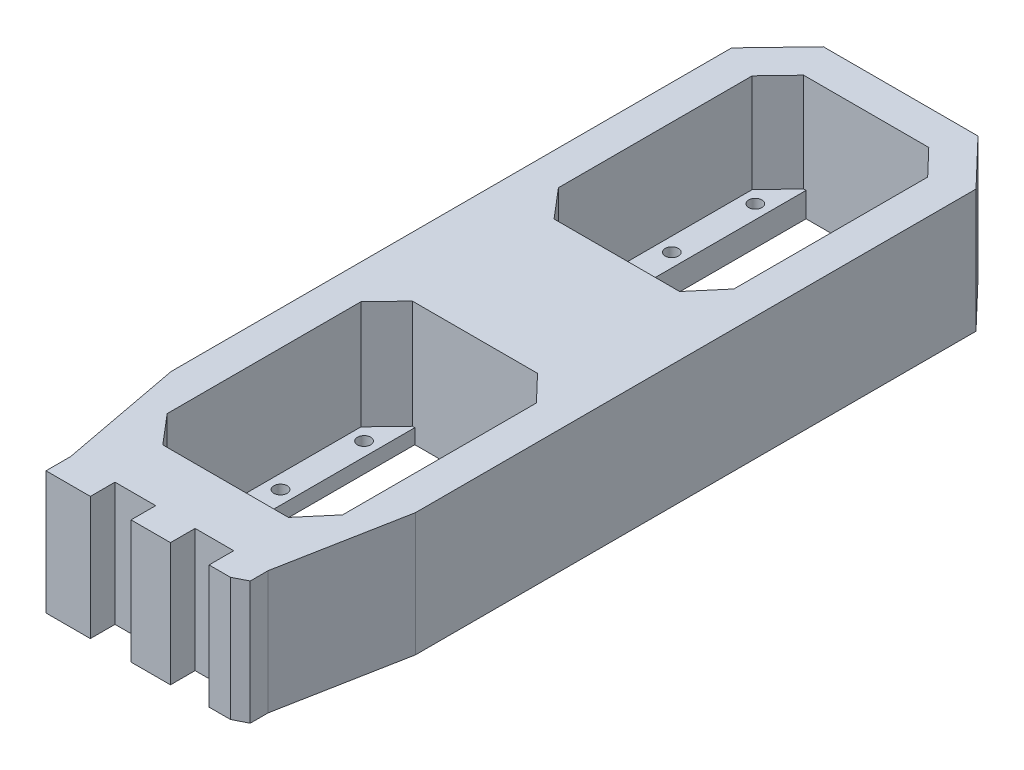
from build123d import *

# Parameters (mm, degrees)
SZKIC1_W                    = 24.4
SZKIC1_H                    = 45
SZKIC1_R                    = 1.35
DODANIE_WYCI_GNI_CIE1_DEPTH = 5
DODANIE_WYCI_GNI_CIE2_DEPTH = 25
SZKIC8_W                    = 8
SZKIC8_H                    = 5
SZKIC8_W_2                  = 9
DODANIE_WYCI_GNI_CIE3_DEPTH = 25
SZKIC1_4_R                  = 1.35
DODANIE_WYCI_GNI_CIE4_DEPTH = 3


with BuildPart() as part:
    # Szkic1 → Dodanie-wyci_gni_cie1 (new body)
    with BuildSketch(Plane(origin=(0, 0, 0), x_dir=(1, 0, 0), z_dir=(0, 1, 0))):
        Polygon((-25.252210447, 194.281753518), (-25.252210447, 80.533497461), (-20.5, 55.3963255), (19.595579106, 55.3963255), (24.347789553, 80.533497461), (24.347789553, 194.281753518), (15.236444388, 203.7963255), (-16.140865282, 203.7963255), align=None)
        with Locations((-0.452210447, 174.2963255)):
            Rectangle(SZKIC1_W, SZKIC1_H, mode=Mode.SUBTRACT)
        with Locations((-15.404420894, 155.2963255)):
            Circle(SZKIC1_R, mode=Mode.SUBTRACT)
        with Locations((-8.952210447, 148.9963255)):
            Circle(SZKIC1_R, mode=Mode.SUBTRACT)
        with Locations((-15.404420894, 172.2963255)):
            Circle(SZKIC1_R, mode=Mode.SUBTRACT)
        with Locations((-15.452210447, 189.2963255)):
            Circle(SZKIC1_R, mode=Mode.SUBTRACT)
        with Locations((8.047789553, 148.9963255)):
            Circle(SZKIC1_R, mode=Mode.SUBTRACT)
        with Locations((14.5, 155.2963255)):
            Circle(SZKIC1_R, mode=Mode.SUBTRACT)
        with Locations((14.5, 172.2963255)):
            Circle(SZKIC1_R, mode=Mode.SUBTRACT)
        with Locations((14.547789553, 189.2963255)):
            Circle(SZKIC1_R, mode=Mode.SUBTRACT)
        Polygon((12.247789553, 117.3963255), (17.347789553, 112.070622628), (17.347789553, 72.740102496), (12.295579106, 66.7963255), (-13.2, 66.7963255), (-18.252210447, 72.740102496), (-18.252210447, 112.070622628), (-13.152210447, 117.3963255), align=None, mode=Mode.SUBTRACT)
    extrude(amount=DODANIE_WYCI_GNI_CIE1_DEPTH)

    # Szkic1_3 → Dodanie-wyci_gni_cie2 (add)
    with BuildSketch(Plane(origin=(0, 0, 0), x_dir=(1, 0, 0), z_dir=(0, 1, 0))):
        Polygon((-20.5, 55.3963255), (19.595579106, 55.3963255), (24.347789553, 80.533497461), (24.347789553, 194.281753518), (15.236444388, 203.7963255), (-16.140865282, 203.7963255), (-25.252210447, 194.281753518), (-25.252210447, 80.533497461), align=None)
        Polygon((-13.152210447, 117.3963255), (12.247789553, 117.3963255), (17.347789553, 112.070622628), (17.347789553, 72.740102496), (12.295579106, 66.7963255), (-13.2, 66.7963255), (-18.252210447, 72.740102496), (-18.252210447, 112.070622628), align=None, mode=Mode.SUBTRACT)
        Polygon((12.247789553, 196.7963255), (17.347789553, 191.470622628), (17.347789553, 152.140102496), (12.295579106, 146.1963255), (-13.2, 146.1963255), (-18.252210447, 152.140102496), (-18.252210447, 191.470622628), (-13.152210447, 196.7963255), align=None, mode=Mode.SUBTRACT)
    extrude(amount=DODANIE_WYCI_GNI_CIE2_DEPTH)

    # Szkic8 → Dodanie-wyci_gni_cie3 (add)
    with BuildSketch(Plane(origin=(0, 25, 0), x_dir=(1, 0, 0), z_dir=(0, 1, 0))):
        Polygon((19.595579106, 51.744454691), (19.595579106, 55.3963255), (12.595579106, 55.3963255), (12.595579106, 50.3963255), (16.925579106, 50.3963255), align=None)
        with Locations((0.758846465, 52.8963255)):
            Rectangle(SZKIC8_W, SZKIC8_H)
        with Locations((-16, 52.8963255)):
            Rectangle(SZKIC8_W_2, SZKIC8_H)
    extrude(amount=-DODANIE_WYCI_GNI_CIE3_DEPTH)

    # Szkic1_4 → Dodanie-wyci_gni_cie4 (add)
    with BuildSketch(Plane(origin=(0, 0, 0), x_dir=(1, 0, 0), z_dir=(0, 1, 0))):
        Polygon((-12.652210447, 72.3963255), (-12.652210447, 117.3963255), (-13.152210447, 117.3963255), (-18.252210447, 112.070622628), (-18.252210447, 72.740102496), (-13.2, 66.7963255), (12.295579106, 66.7963255), (17.347789553, 72.740102496), (17.347789553, 112.070622628), (12.247789553, 117.3963255), (11.747789553, 117.3963255), (11.747789553, 72.3963255), align=None)
        with Locations((-15.404420894, 75.8963255)):
            Circle(SZKIC1_4_R, mode=Mode.SUBTRACT)
        with Locations((-8.952210447, 69.5963255)):
            Circle(SZKIC1_4_R, mode=Mode.SUBTRACT)
        with Locations((-15.404420894, 92.8963255)):
            Circle(SZKIC1_4_R, mode=Mode.SUBTRACT)
        with Locations((-15.452210447, 109.8963255)):
            Circle(SZKIC1_4_R, mode=Mode.SUBTRACT)
        with Locations((8.047789553, 69.5963255)):
            Circle(SZKIC1_4_R, mode=Mode.SUBTRACT)
        with Locations((14.5, 75.8963255)):
            Circle(SZKIC1_4_R, mode=Mode.SUBTRACT)
        with Locations((14.5, 92.8963255)):
            Circle(SZKIC1_4_R, mode=Mode.SUBTRACT)
        with Locations((14.547789553, 109.8963255)):
            Circle(SZKIC1_4_R, mode=Mode.SUBTRACT)
    extrude(amount=DODANIE_WYCI_GNI_CIE4_DEPTH)


solid = part.part
